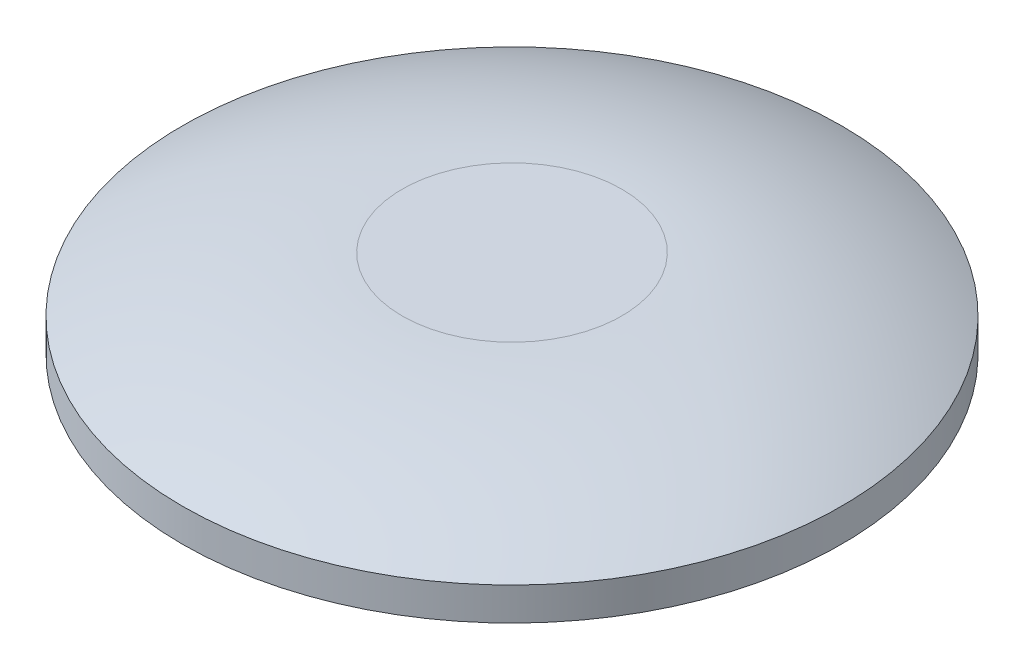
from build123d import *


with BuildPart() as part:
    # Sketch1 → Revolve1 (revolve)
    with BuildSketch(Plane.XY):
        with BuildLine():
            Line((0, 0), (10, 0))
            Line((10, 0), (10, 1))
            Line((10, 1), (15, 1))
            Line((15, 1), (15, 2.5))
            ThreePointArc((15, 2.5), (10.153882032, 4.365528128), (5, 5))
            Line((5, 5), (0, 5))
            Line((0, 5), (0, 0))
        make_face()
    revolve(axis=Axis((0, 0, 0), (0, 1, 0)))


solid = part.part
